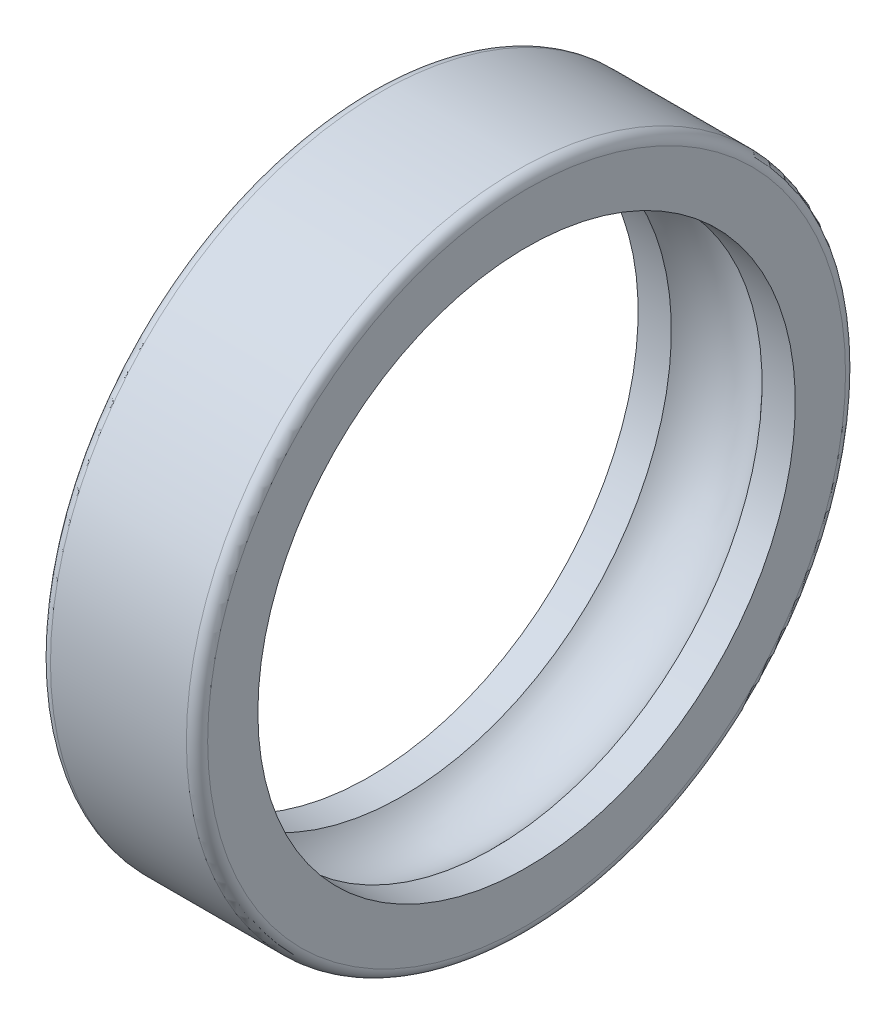
from build123d import *

# Parameters (mm, degrees)
FILLET1_R = 2.1


with BuildPart() as part:
    # Sketch1 → Revolve1 (revolve)
    with BuildSketch(Plane.XY):
        with BuildLine():
            Line((-15.5, 65), (15.5, 65))
            Line((15.5, 65), (15.5, 53))
            Line((15.5, 53), (8.94427191, 53))
            ThreePointArc((8.94427191, 53), (0, 57), (-8.94427191, 53))
            Line((-8.94427191, 53), (-15.5, 53))
            Line((-15.5, 53), (-15.5, 65))
        make_face()
    revolve(axis=Axis((-19.179032775, 0, 0), (1, 0, 0)))

    # Fillet1
    fillet1_edges = [part.edges().sort_by_distance(p)[0] for p in [
        (-15.5, -65, 0),
        (15.5, -65, 0),
    ]]
    fillet(fillet1_edges, radius=FILLET1_R)


solid = part.part
